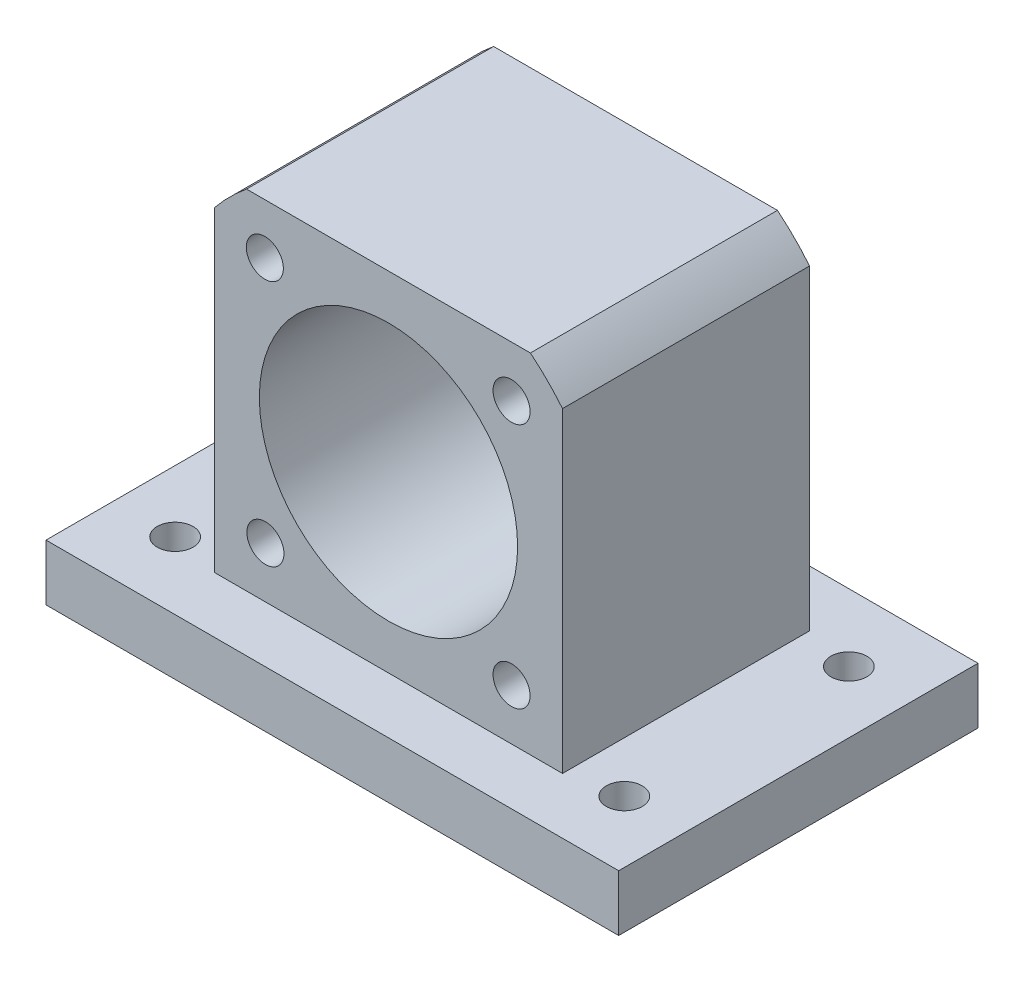
from build123d import *

# Parameters (mm, degrees)
EXTRUDE_1_DEPTH             = 11
CUT_EXTRUDE_1_REACH         = 24
SKETCH_2_R                  = 11.5
HOLE_WIZARD_M4_1_D          = 3.3
HOLE_WIZARD_M4_1_DEPTH      = 10.1
HOLE_WIZARD_M4_1_TIP        = 0.991420021
SKETCH_9_W                  = 51
SKETCH_9_H                  = 32
EXTRUDE_2_DEPTH             = 5
HOLE_WIZARD_3_2_3_2_1_D     = 3.2
HOLE_WIZARD_3_2_3_2_1_DEPTH = 5


with BuildPart() as part:
    # 草图1 → 凸台-拉伸1 (new body, symmetric)
    with BuildSketch(Plane.XY):
        with BuildLine():
            Line((15.5, -15.5), (-15.5, -15.5))
            Line((-15.5, -15.5), (-15.5, 12.63922466))
            ThreePointArc((-15.5, 12.63922466), (-14.142135624, 14.142135624), (-12.63922466, 15.5))
            Line((-12.63922466, 15.5), (12.63922466, 15.5))
            ThreePointArc((12.63922466, 15.5), (14.142135624, 14.142135624), (15.5, 12.63922466))
            Line((15.5, 12.63922466), (15.5, -15.5))
        make_face()
    extrude(amount=EXTRUDE_1_DEPTH, both=True)

    # 草图2 → 切除-拉伸1 (cut, up to next)
    with BuildSketch(Plane.XY.offset(11), mode=Mode.PRIVATE) as cut_extrude_1_sk1:
        Circle(SKETCH_2_R)
    cut_extrude_1_tool1 = extrude(cut_extrude_1_sk1.sketch, amount=-CUT_EXTRUDE_1_REACH, mode=Mode.PRIVATE) & part.part
    add(cut_extrude_1_tool1.solids().sort_by_distance((0, 0, 11))[0], mode=Mode.SUBTRACT)

    # M4 螺纹孔1
    with Locations(Plane.XY.offset(11)):
        with Locations((-11.012100522, 11.012100522), (10.960155108, 10.960155108), (10.960155108, -10.960155108), (-10.960155108, -10.960155108)):
            Hole(HOLE_WIZARD_M4_1_D / 2, depth=HOLE_WIZARD_M4_1_DEPTH)
            with Locations((0, 0, -(HOLE_WIZARD_M4_1_DEPTH + HOLE_WIZARD_M4_1_TIP / 2))):  # 118° drill point
                Cone(0, HOLE_WIZARD_M4_1_D / 2, HOLE_WIZARD_M4_1_TIP, mode=Mode.SUBTRACT)

    # 草图9 → 凸台-拉伸2 (add)
    with BuildSketch(Plane.XZ.offset(15.5)):
        Rectangle(SKETCH_9_W, SKETCH_9_H)
    extrude(amount=EXTRUDE_2_DEPTH)

    # Ø3.2 (3.2) 直径孔1
    with Locations(Plane(origin=(0, -20.5, 0), x_dir=(-1, 0, 0), z_dir=(0, -1, 0))):
        with Locations((20, -10), (-20, -10), (-20, 10), (20, 10)):
            Hole(HOLE_WIZARD_3_2_3_2_1_D / 2, depth=HOLE_WIZARD_3_2_3_2_1_DEPTH)


solid = part.part
